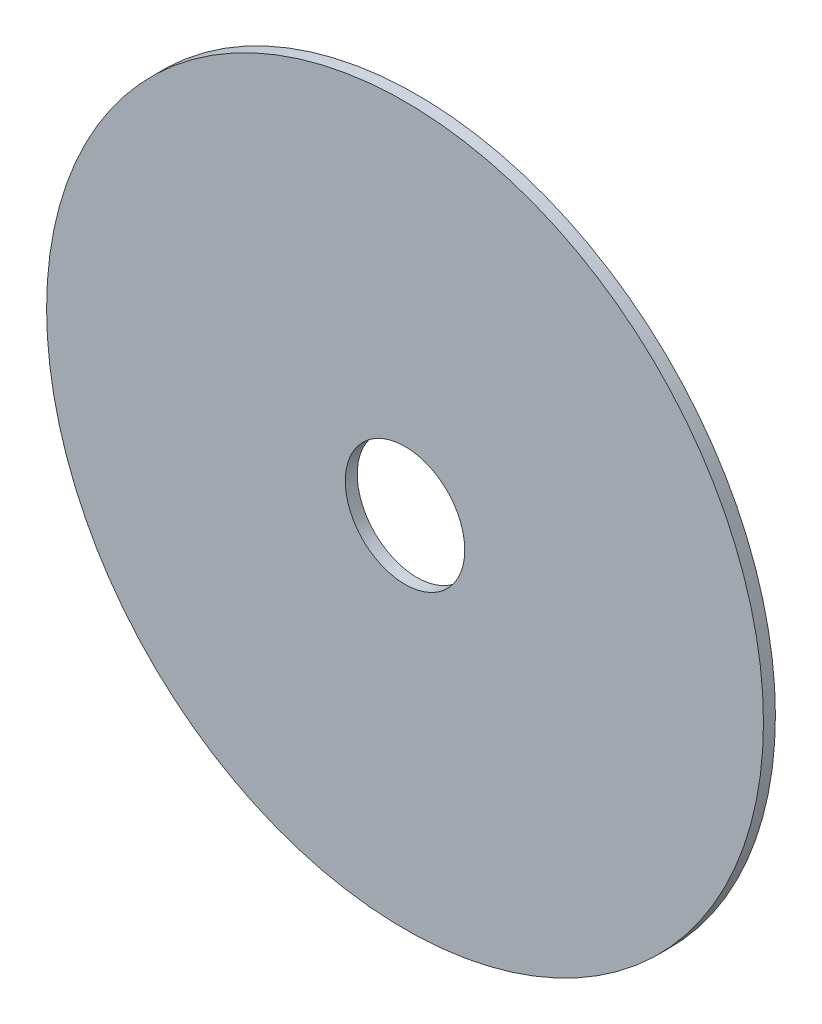
from build123d import *

# Parameters (mm, degrees)
SKETCH1_R           = 30
BOSS_EXTRUDE1_DEPTH = 1
SKETCH2_R           = 5
CUT_EXTRUDE1_DEPTH  = 4


with BuildPart() as part:
    # Sketch1 → Boss-Extrude1 (new body)
    with BuildSketch(Plane.XY):
        Circle(SKETCH1_R)
    extrude(amount=BOSS_EXTRUDE1_DEPTH)

    # Sketch2 → Cut-Extrude1 (cut)
    with BuildSketch(Plane.XY.offset(1)):
        Circle(SKETCH2_R)
    extrude(amount=-CUT_EXTRUDE1_DEPTH, mode=Mode.SUBTRACT)


solid = part.part
